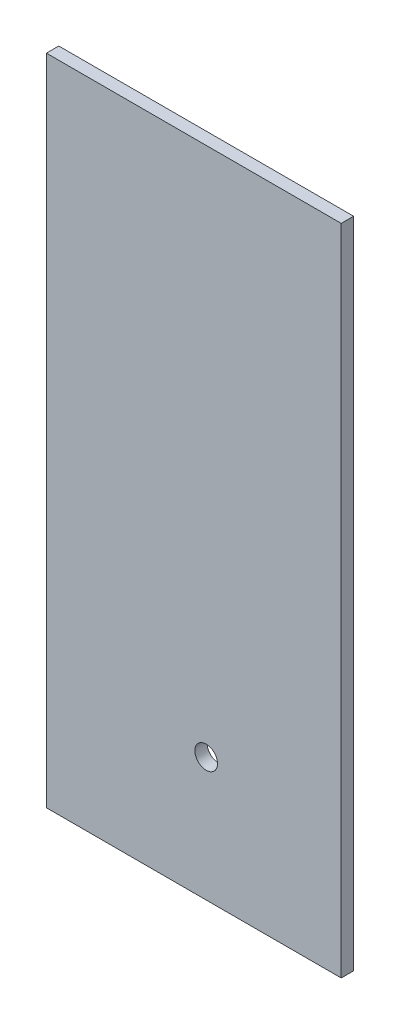
from build123d import *

# Parameters (mm, degrees)
SKETCH1_W           = 143
SKETCH1_H           = 317
BOSS_EXTRUDE1_DEPTH = 6
SKETCH2_R           = 5.5
CUT_EXTRUDE1_DEPTH  = 7


with BuildPart() as part:
    # Sketch1 → Boss-Extrude1 (new body)
    with BuildSketch(Plane.XY):
        Rectangle(SKETCH1_W, SKETCH1_H)
    extrude(amount=BOSS_EXTRUDE1_DEPTH)

    # Sketch2 → Cut-Extrude1 (cut, through all)
    with BuildSketch(Plane.XY.offset(6)):
        with Locations((6, -98.5)):
            Circle(SKETCH2_R)
    extrude(amount=-CUT_EXTRUDE1_DEPTH, mode=Mode.SUBTRACT)


solid = part.part
